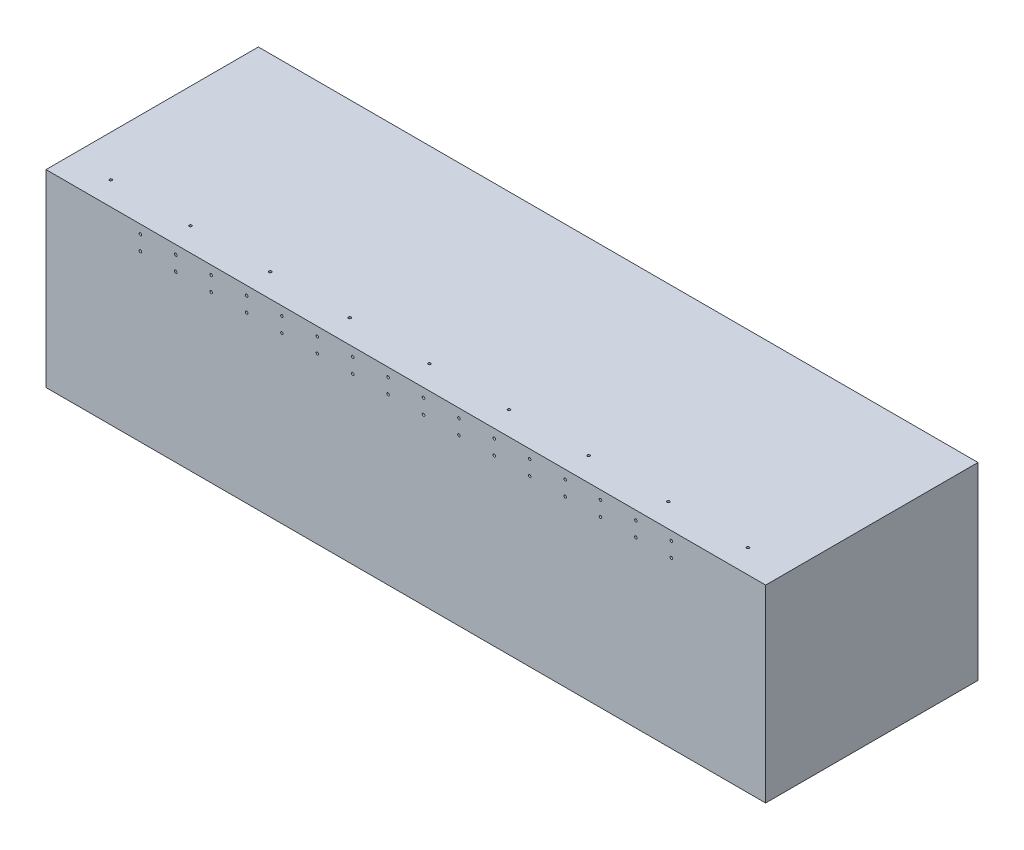
from build123d import *

# Parameters (mm, degrees)
SKETCH1_W           = 1549.4
SKETCH1_H           = 457.2
BOSS_EXTRUDE1_DEPTH = 406.4
HOLE1_D             = 5.588
HOLE1_DEPTH         = 5.08
LPATTERN1_COUNT     = 3
LPATTERN1_PITCH     = 50.8
HOLE2_D             = 5.588
HOLE2_DEPTH         = 5.08
LPATTERN2_COUNT     = 16
LPATTERN2_PITCH     = 76.2
HOLE3_D             = 5.588
HOLE3_DEPTH         = 5.08
LPATTERN3_COUNT     = 9
LPATTERN3_PITCH     = 171.45


with BuildPart() as part:
    # Sketch1 → Boss-Extrude1 (new body)
    with BuildSketch(Plane(origin=(0, 0, 0), x_dir=(1, 0, 0), z_dir=(0, 1, 0))):
        with Locations((774.7, 228.6)):
            Rectangle(SKETCH1_W, SKETCH1_H)
    extrude(amount=-BOSS_EXTRUDE1_DEPTH)

    # Hole1
    with Locations(Plane(origin=(15.875, -25.4, -457.2), x_dir=(-1, 0, 0), z_dir=(0, 0, -1))):
        with Locations((0, 0), (-1517.65, 0)):
            hole1 = Hole(HOLE1_D / 2, depth=HOLE1_DEPTH)

    # LPattern1: Hole1 ×3
    with Locations(*[(0, -i * LPATTERN1_PITCH, 0) for i in range(1, LPATTERN1_COUNT)]):
        add(hole1, mode=Mode.SUBTRACT)

    # Hole2
    with Locations(Plane(origin=(203.2, -19.05, 0), x_dir=(1, 0, 0), z_dir=(0, 0, 1))):
        with Locations((0, 0), (0, -31.75)):
            hole2 = Hole(HOLE2_D / 2, depth=HOLE2_DEPTH)

    # LPattern2: Hole2 ×16
    with Locations(*[(i * LPATTERN2_PITCH, 0, 0) for i in range(1, LPATTERN2_COUNT)]):
        add(hole2, mode=Mode.SUBTRACT)

    # Hole3
    with Locations(Plane(origin=(88.9, 0, -50.8), x_dir=(0, 0, 1), z_dir=(0, 1, 0))):
        with Locations((0, 0)):
            hole3 = Hole(HOLE3_D / 2, depth=HOLE3_DEPTH)

    # LPattern3: Hole3 ×9
    with Locations(*[(i * LPATTERN3_PITCH, 0, 0) for i in range(1, LPATTERN3_COUNT)]):
        add(hole3, mode=Mode.SUBTRACT)


solid = part.part
